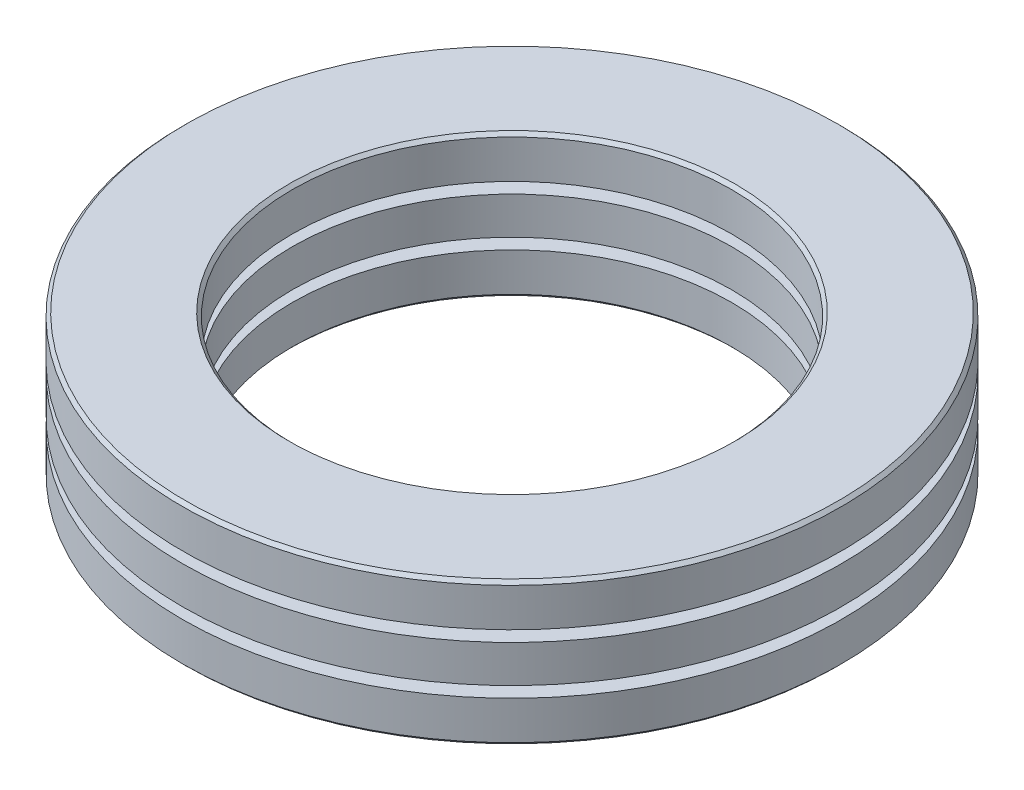
from build123d import *

# Parameters (mm, degrees)
SKETCH1_R           = 30
SKETCH1_R_2         = 20
BOSS_EXTRUDE1_DEPTH = 3.8
SKETCH2_R           = 30
SKETCH2_R_2         = 20
BOSS_EXTRUDE2_DEPTH = 3.4
SKETCH3_R           = 30
SKETCH3_R_2         = 20
BOSS_EXTRUDE3_DEPTH = 3.8
CIRPATTERN1_COUNT   = 18
CIRPATTERN4_COUNT   = 18
CHAMFER1_SIZE       = 0.3
CHAMFER2_SIZE       = 0.3


with BuildPart() as part:
    # Sketch1 → Boss-Extrude1 (new body)
    with BuildSketch(Plane(origin=(0, 0, 0), x_dir=(1, 0, 0), z_dir=(0, 1, 0))):
        Circle(SKETCH1_R)
        Circle(SKETCH1_R_2, mode=Mode.SUBTRACT)
    extrude(amount=BOSS_EXTRUDE1_DEPTH)

    # Chamfer1
    chamfer1_edges = [part.edges().sort_by_distance(p)[0] for p in [
        (-30, 0, 0),
        (-20, 0, 0),
    ]]
    chamfer(chamfer1_edges, length=CHAMFER1_SIZE)


with BuildPart() as body_2:
    # Sketch2 → Boss-Extrude2 (new body)
    with BuildSketch(Plane(origin=(0, 4.8, 0), x_dir=(1, 0, 0), z_dir=(0, 1, 0))):
        Circle(SKETCH2_R)
        Circle(SKETCH2_R_2, mode=Mode.SUBTRACT)
    extrude(amount=BOSS_EXTRUDE2_DEPTH)

    # Sketch4 → Cut-Revolve2 (revolve, cut)
    with BuildSketch(Plane.XY):
        with BuildLine():
            Line((-27.7, 6.5), (-22.3, 6.5))
            ThreePointArc((-22.3, 6.5), (-25, 9.2), (-27.7, 6.5))
        make_face()
    cut_revolve2 = revolve(axis=Axis((-27.7, 6.5, 0), (1, 0, 0)), mode=Mode.SUBTRACT)

    # CirPattern1: Cut-Revolve2 ×18 about axis
    cirpattern1_axis = Axis((0, 0, 0), (0, -1, 0))
    for i in range(1, CIRPATTERN1_COUNT):
        add(cut_revolve2.rotate(cirpattern1_axis, i * 360 / CIRPATTERN1_COUNT), mode=Mode.SUBTRACT)


with BuildPart() as body_3:
    # Sketch3 → Boss-Extrude3 (new body)
    with BuildSketch(Plane(origin=(0, 13, 0), x_dir=(-1, 0, 0), z_dir=(0, -1, 0))):
        Circle(SKETCH3_R)
        Circle(SKETCH3_R_2, mode=Mode.SUBTRACT)
    extrude(amount=BOSS_EXTRUDE3_DEPTH)

    # Chamfer2
    chamfer2_edges = [body_3.edges().sort_by_distance(p)[0] for p in [
        (30, 13, 0),
        (20, 13, 0),
    ]]
    chamfer(chamfer2_edges, length=CHAMFER2_SIZE)


with BuildPart() as body_4:
    # Sketch4_3 → Revolve1 (revolve)
    with BuildSketch(Plane.XY):
        with BuildLine():
            Line((-27.7, 6.5), (-22.3, 6.5))
            ThreePointArc((-22.3, 6.5), (-25, 9.2), (-27.7, 6.5))
        make_face()
    revolve(axis=Axis((-27.7, 6.5, 0), (1, 0, 0)))


with BuildPart() as cirpattern4_1:
    # CirPattern4: pattern copy
    add(body_4.part.rotate(Axis((0, 0, 0), (0, -1, 0)), 1 * 360 / CIRPATTERN4_COUNT))


with BuildPart() as cirpattern4_2:
    # CirPattern4: pattern copy
    add(body_4.part.rotate(Axis((0, 0, 0), (0, -1, 0)), 2 * 360 / CIRPATTERN4_COUNT))


with BuildPart() as cirpattern4_3:
    # CirPattern4: pattern copy
    add(body_4.part.rotate(Axis((0, 0, 0), (0, -1, 0)), 3 * 360 / CIRPATTERN4_COUNT))


with BuildPart() as cirpattern4_4:
    # CirPattern4: pattern copy
    add(body_4.part.rotate(Axis((0, 0, 0), (0, -1, 0)), 4 * 360 / CIRPATTERN4_COUNT))


with BuildPart() as cirpattern4_5:
    # CirPattern4: pattern copy
    add(body_4.part.rotate(Axis((0, 0, 0), (0, -1, 0)), 5 * 360 / CIRPATTERN4_COUNT))


with BuildPart() as cirpattern4_6:
    # CirPattern4: pattern copy
    add(body_4.part.rotate(Axis((0, 0, 0), (0, -1, 0)), 6 * 360 / CIRPATTERN4_COUNT))


with BuildPart() as cirpattern4_7:
    # CirPattern4: pattern copy
    add(body_4.part.rotate(Axis((0, 0, 0), (0, -1, 0)), 7 * 360 / CIRPATTERN4_COUNT))


with BuildPart() as cirpattern4_8:
    # CirPattern4: pattern copy
    add(body_4.part.rotate(Axis((0, 0, 0), (0, -1, 0)), 8 * 360 / CIRPATTERN4_COUNT))


with BuildPart() as cirpattern4_9:
    # CirPattern4: pattern copy
    add(body_4.part.rotate(Axis((0, 0, 0), (0, -1, 0)), 9 * 360 / CIRPATTERN4_COUNT))


with BuildPart() as cirpattern4_10:
    # CirPattern4: pattern copy
    add(body_4.part.rotate(Axis((0, 0, 0), (0, -1, 0)), 10 * 360 / CIRPATTERN4_COUNT))


with BuildPart() as cirpattern4_11:
    # CirPattern4: pattern copy
    add(body_4.part.rotate(Axis((0, 0, 0), (0, -1, 0)), 11 * 360 / CIRPATTERN4_COUNT))


with BuildPart() as cirpattern4_12:
    # CirPattern4: pattern copy
    add(body_4.part.rotate(Axis((0, 0, 0), (0, -1, 0)), 12 * 360 / CIRPATTERN4_COUNT))


with BuildPart() as cirpattern4_13:
    # CirPattern4: pattern copy
    add(body_4.part.rotate(Axis((0, 0, 0), (0, -1, 0)), 13 * 360 / CIRPATTERN4_COUNT))


with BuildPart() as cirpattern4_14:
    # CirPattern4: pattern copy
    add(body_4.part.rotate(Axis((0, 0, 0), (0, -1, 0)), 14 * 360 / CIRPATTERN4_COUNT))


with BuildPart() as cirpattern4_15:
    # CirPattern4: pattern copy
    add(body_4.part.rotate(Axis((0, 0, 0), (0, -1, 0)), 15 * 360 / CIRPATTERN4_COUNT))


with BuildPart() as cirpattern4_16:
    # CirPattern4: pattern copy
    add(body_4.part.rotate(Axis((0, 0, 0), (0, -1, 0)), 16 * 360 / CIRPATTERN4_COUNT))


with BuildPart() as cirpattern4_17:
    # CirPattern4: pattern copy
    add(body_4.part.rotate(Axis((0, 0, 0), (0, -1, 0)), 17 * 360 / CIRPATTERN4_COUNT))


solid = Compound([part.part, body_2.part, body_3.part, body_4.part, cirpattern4_1.part, cirpattern4_2.part, cirpattern4_3.part, cirpattern4_4.part, cirpattern4_5.part, cirpattern4_6.part, cirpattern4_7.part, cirpattern4_8.part, cirpattern4_9.part, cirpattern4_10.part, cirpattern4_11.part, cirpattern4_12.part, cirpattern4_13.part, cirpattern4_14.part, cirpattern4_15.part, cirpattern4_16.part, cirpattern4_17.part])
